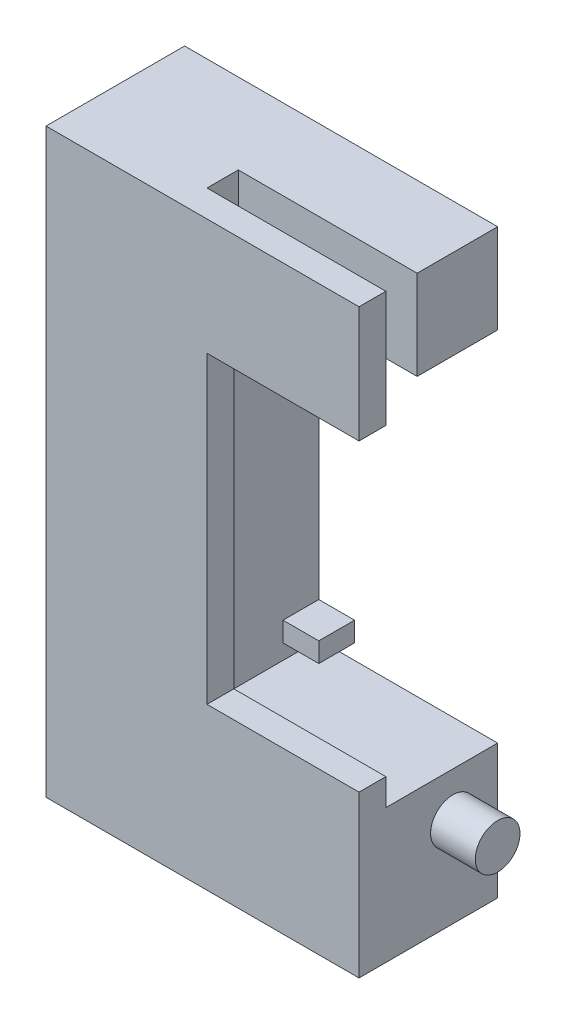
from build123d import *

# Parameters (mm, degrees)
BOSS_EXTRUDE1_DEPTH      = 8.5
BOSS_EXTRUDE1_DEPTH_BACK = 4
SKETCH3_W                = 40
SKETCH3_H                = 3.5
CUT_EXTRUDE1_DEPTH       = 10
BOSS_EXTRUDE2_DEPTH      = 3
SKETCH5_R                = 2.5
BOSS_EXTRUDE3_DEPTH      = 5
SKETCH6_W                = 4
SKETCH6_H                = 2.2
BOSS_EXTRUDE4_DEPTH      = 4


with BuildPart() as part:
    # Sketch1 → Boss-Extrude1 (new body, two sides)
    with BuildSketch(Plane.XY) as boss_extrude1_sk:
        Polygon((0, 0), (0, 65), (35, 65), (35, 55), (15, 55), (15, 15), (35, 15), (35, 0), align=None)
    extrude(amount=BOSS_EXTRUDE1_DEPTH)
    extrude(boss_extrude1_sk.sketch, amount=-BOSS_EXTRUDE1_DEPTH_BACK)

    # Sketch3 → Cut-Extrude1 (cut)
    with BuildSketch(Plane(origin=(0, 65, 0), x_dir=(1, 0, 0), z_dir=(0, 1, 0))):
        with Locations((35, -6.75)):
            Rectangle(SKETCH3_W, SKETCH3_H)
    extrude(amount=-CUT_EXTRUDE1_DEPTH, mode=Mode.SUBTRACT)

    # Sketch4 → Boss-Extrude2 (add)
    with BuildSketch(Plane.XY.offset(8.5)):
        Polygon((35, 0), (0, 0), (0, 65), (35, 65), (35, 52), (18, 52), (18, 18), (35, 18), align=None)
    extrude(amount=BOSS_EXTRUDE2_DEPTH)

    # Sketch5 → Boss-Extrude3 (add)
    with BuildSketch(Plane(origin=(35, 0, 0), x_dir=(0, 0, -1), z_dir=(1, 0, 0))):
        with Locations((-1, 10)):
            Circle(SKETCH5_R)
    extrude(amount=BOSS_EXTRUDE3_DEPTH)

    # Sketch6 → Boss-Extrude4 (add)
    with BuildSketch(Plane(origin=(15, 0, 0), x_dir=(0, 0, -1), z_dir=(1, 0, 0))):
        with Locations((2, 52.2)):
            Rectangle(SKETCH6_W, SKETCH6_H)
        with Locations((2, 17.8)):
            Rectangle(SKETCH6_W, SKETCH6_H)
    extrude(amount=BOSS_EXTRUDE4_DEPTH)


solid = part.part
